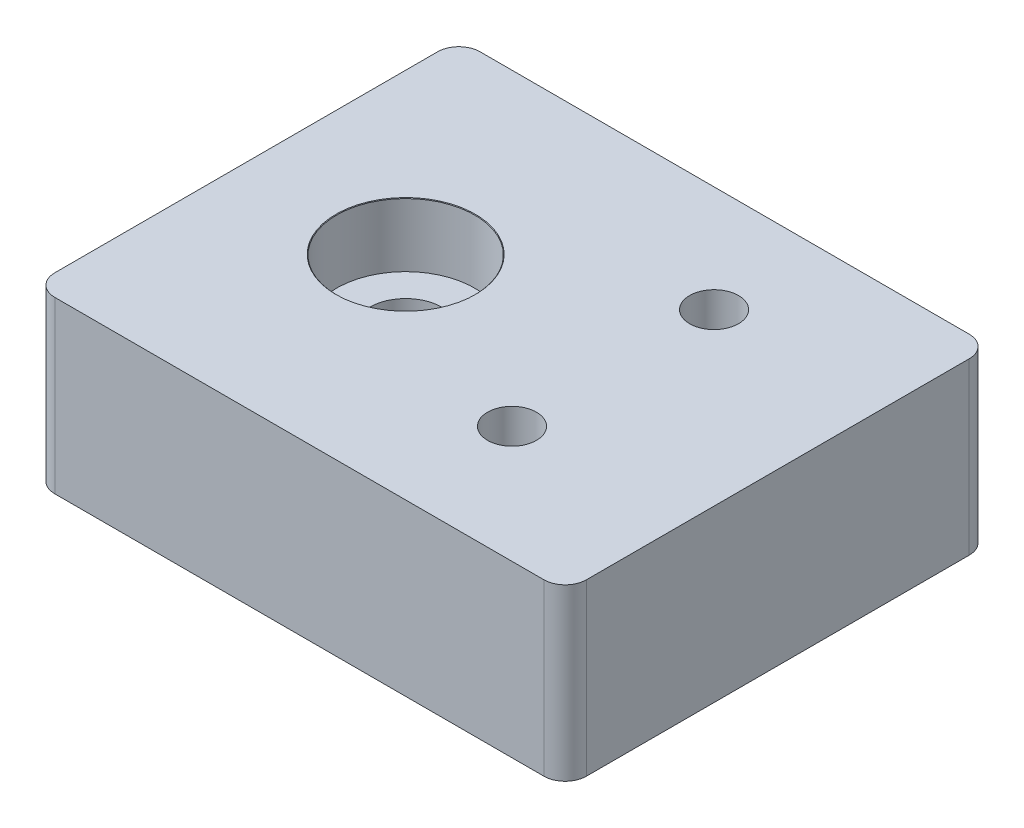
from build123d import *

# Parameters (mm, degrees)
SKETCH1_W           = 25
SKETCH1_H           = 20
BOSS_EXTRUDE1_DEPTH = 8
FILLET1_R           = 1
SKETCH5_R           = 1.15
CUT_EXTRUDE1_DEPTH  = 5


with BuildPart() as part:
    # Sketch1 → Boss-Extrude1 (new body)
    with BuildSketch(Plane(origin=(0, 0, 0), x_dir=(1, 0, 0), z_dir=(0, 1, 0))):
        Rectangle(SKETCH1_W, SKETCH1_H)
    extrude(amount=BOSS_EXTRUDE1_DEPTH)

    # Sketch4 → CBORE for M3 SHCS1 (revolve, cut)
    with BuildSketch(Plane(origin=(-5, 8, 0), x_dir=(0, 0, 1), z_dir=(1, 0, 0))):
        Polygon((0, 0), (0, 8), (1.7, 8), (1.7, 3), (3.25, 3), (3.25, 0.025), (3.275, 0), align=None)
    revolve(axis=Axis((-5, 14.35, 0), (0, -1, 0)), mode=Mode.SUBTRACT)

    # Fillet1
    fillet1_edges = [part.edges().sort_by_distance(p)[0] for p in [
        (-12.5, 4, -10),
        (12.5, 4, -10),
        (12.5, 4, 10),
        (-12.5, 4, 10),
    ]]
    fillet(fillet1_edges, radius=FILLET1_R)

    # Sketch5 → Cut-Extrude1 (cut)
    with BuildSketch(Plane(origin=(0, 8, 0), x_dir=(1, 0, 0), z_dir=(0, 1, 0))):
        with Locations((4.5, 5)):
            Circle(SKETCH5_R)
        with Locations((4.5, -4.5)):
            Circle(SKETCH5_R)
    extrude(amount=-CUT_EXTRUDE1_DEPTH, mode=Mode.SUBTRACT)


solid = part.part
